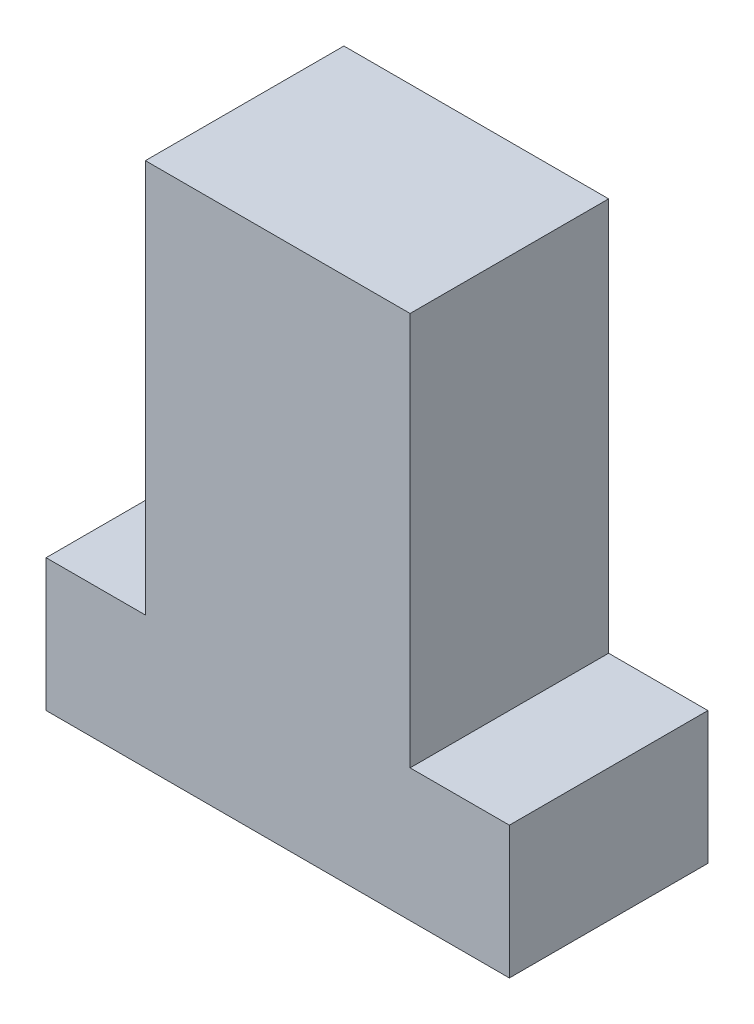
from build123d import *

# Parameters (mm, degrees)
SKETCH1_W           = 40
SKETCH1_H           = 59.46
SKETCH1_W_2         = 70
SKETCH1_H_2         = 20
BOSS_EXTRUDE1_DEPTH = 30


with BuildPart() as part:
    # Sketch1 → Boss-Extrude1 (new body)
    with BuildSketch(Plane.XY):
        with Locations((0, 39.73)):
            Rectangle(SKETCH1_W, SKETCH1_H)
        Rectangle(SKETCH1_W_2, SKETCH1_H_2)
    extrude(amount=BOSS_EXTRUDE1_DEPTH)


solid = part.part
